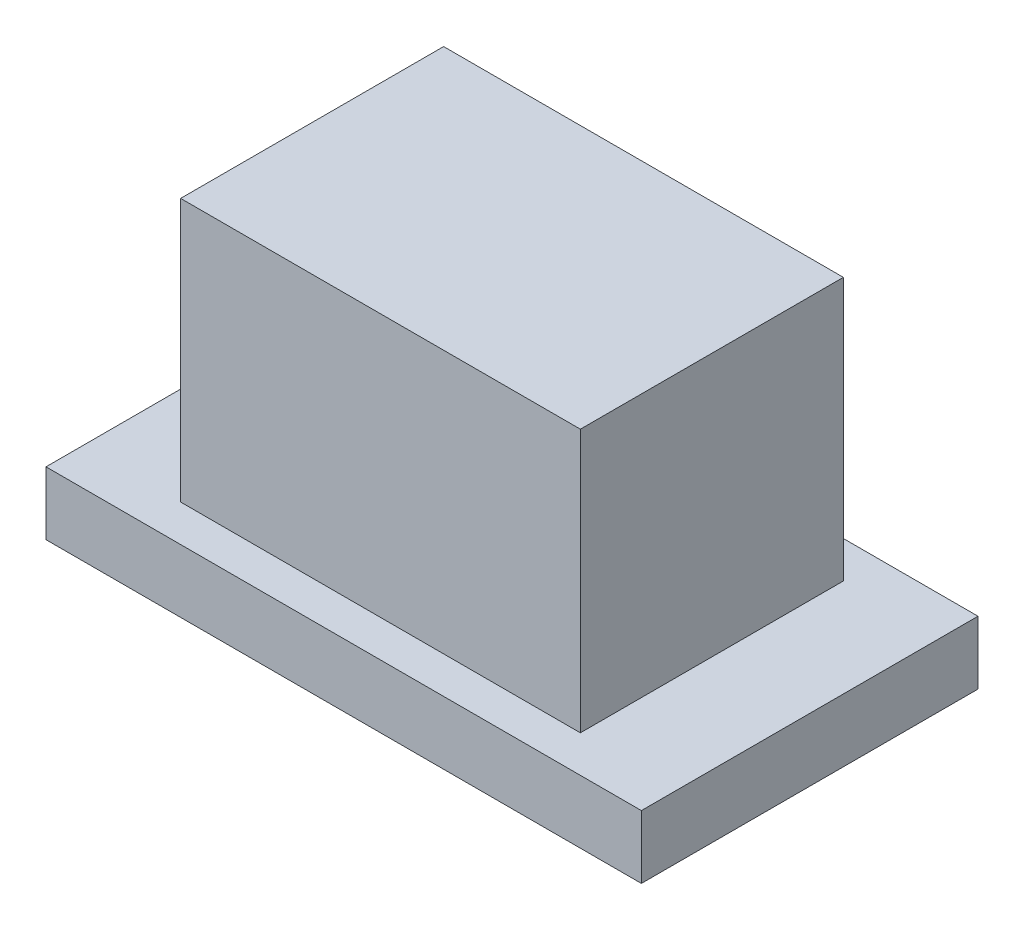
from build123d import *

# Parameters (mm, degrees)
SKETCH1_W           = 28.3
SKETCH1_H           = 16
BOSS_EXTRUDE1_DEPTH = 3
SKETCH2_W           = 19
SKETCH2_H           = 12.5
BOSS_EXTRUDE2_DEPTH = 12.5


with BuildPart() as part:
    # Sketch1 → Boss-Extrude1 (new body)
    with BuildSketch(Plane(origin=(0, 0, 0), x_dir=(1, 0, 0), z_dir=(0, 1, 0))):
        with Locations((5.486734694, -1.962755102)):
            Rectangle(SKETCH1_W, SKETCH1_H)
    extrude(amount=BOSS_EXTRUDE1_DEPTH)

    # Sketch2 → Boss-Extrude2 (add)
    with BuildSketch(Plane(origin=(0, 3, 0), x_dir=(1, 0, 0), z_dir=(0, 1, 0))):
        with Locations((5.486734694, -1.962755102)):
            Rectangle(SKETCH2_W, SKETCH2_H)
    extrude(amount=BOSS_EXTRUDE2_DEPTH)


solid = part.part
